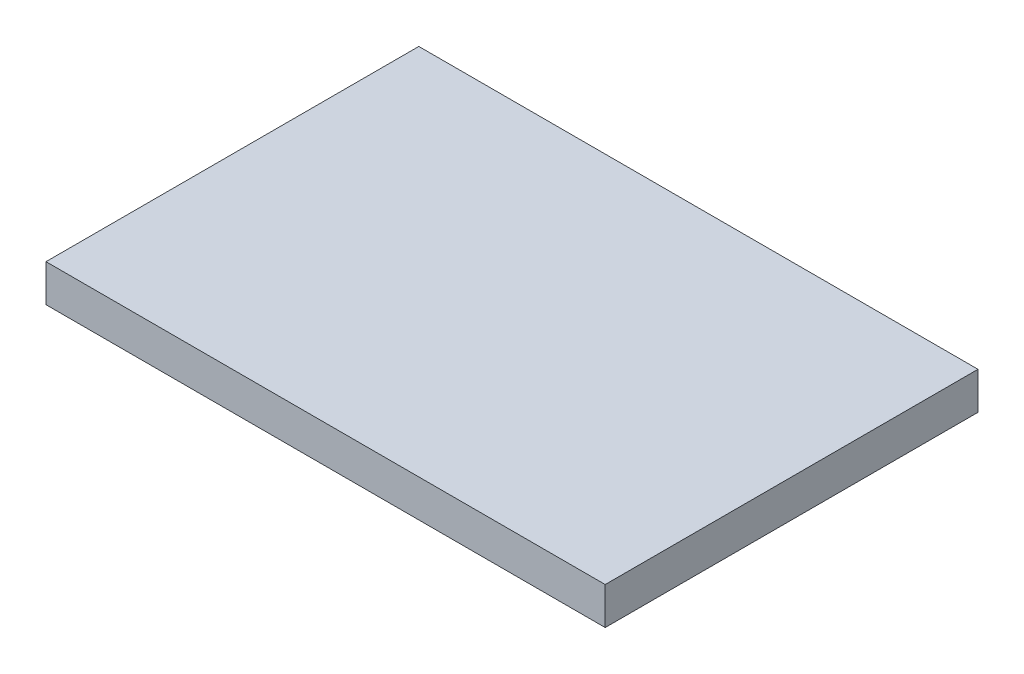
from build123d import *

# Parameters (mm, degrees)
SKETCH1_W           = 60
SKETCH1_H           = 40
BOSS_EXTRUDE1_DEPTH = 4


with BuildPart() as part:
    # Sketch1 → Boss-Extrude1 (new body)
    with BuildSketch(Plane(origin=(0, 0, 0), x_dir=(1, 0, 0), z_dir=(0, 1, 0))):
        with Locations((-31.84501845, -0.073800738)):
            Rectangle(SKETCH1_W, SKETCH1_H)
    extrude(amount=BOSS_EXTRUDE1_DEPTH)


solid = part.part
